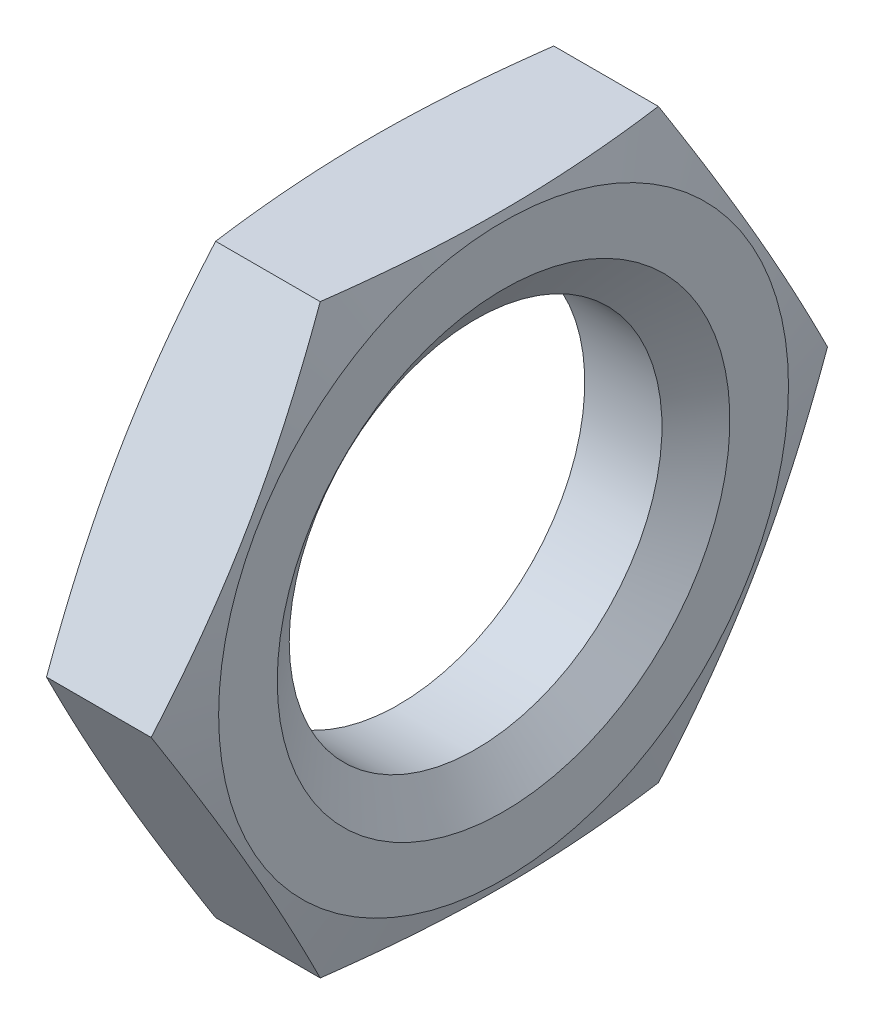
from build123d import *

# Parameters (mm, degrees)
EXTRUDE_1_DEPTH = 2.5


with BuildPart() as part:
    # Эскиз1 → Бобышка-Вытянуть1 (new body)
    with BuildSketch(Plane(origin=(0, 0, 0), x_dir=(0, 0, -1), z_dir=(1, 0, 0))):
        Polygon((6.350852961, 0), (3.175426481, 5.5), (-3.175426481, 5.5), (-6.350852961, 0), (-3.175426481, -5.5), (3.175426481, -5.5), align=None)
    extrude(amount=EXTRUDE_1_DEPTH)

    # Эскиз2 → Вырез-Повернуть1 (revolve, cut)
    with BuildSketch(Plane(origin=(0, 0, 0), x_dir=(1, 0, 0), z_dir=(0, 1, 0))):
        Polygon((0, 5.350852961), (0.267949192, 6.350852961), (2.232050808, 6.350852961), (2.5, 5.350852961), (4.577096119, 5.350852961), (4.577096119, 7.799096081), (-1.908033153, 7.799096081), (-1.908033153, 5.350852961), align=None)
    revolve(axis=Axis((0, 0, 0), (1, 0, 0)), mode=Mode.SUBTRACT)

    # Эскиз3 → Отверстие обработанное метчиком M8x1.01 (revolve, cut)
    with BuildSketch(Plane.ZX):
        Polygon((0, 0), (0, 2.5), (4.25, 2.5), (3.5, 1.974844346), (3.5, 0.525155654), (4.25, 0), align=None)
    revolve(axis=Axis((-6.35, 0, 0), (1, 0, 0)), mode=Mode.SUBTRACT)


solid = part.part
